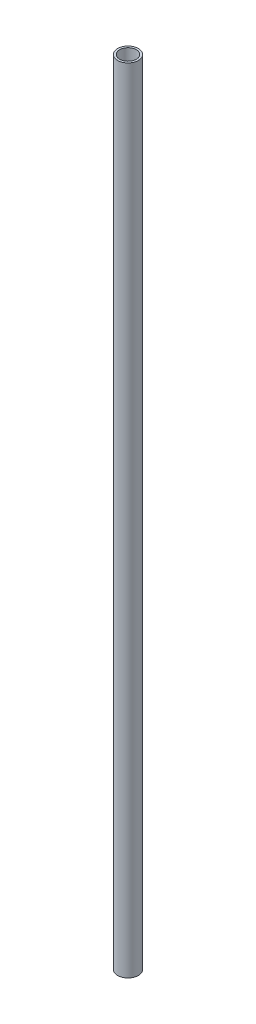
from build123d import *

# Parameters (mm, degrees)
SKETCH_1_R      = 10
SKETCH_1_R_2    = 8
EXTRUDE_1_DEPTH = 763


with BuildPart() as part:
    # 草图1 → 凸台-拉伸1 (new body)
    with BuildSketch(Plane(origin=(0, 0, 0), x_dir=(1, 0, 0), z_dir=(0, 1, 0))):
        Circle(SKETCH_1_R)
        Circle(SKETCH_1_R_2, mode=Mode.SUBTRACT)
    extrude(amount=EXTRUDE_1_DEPTH)


solid = part.part
